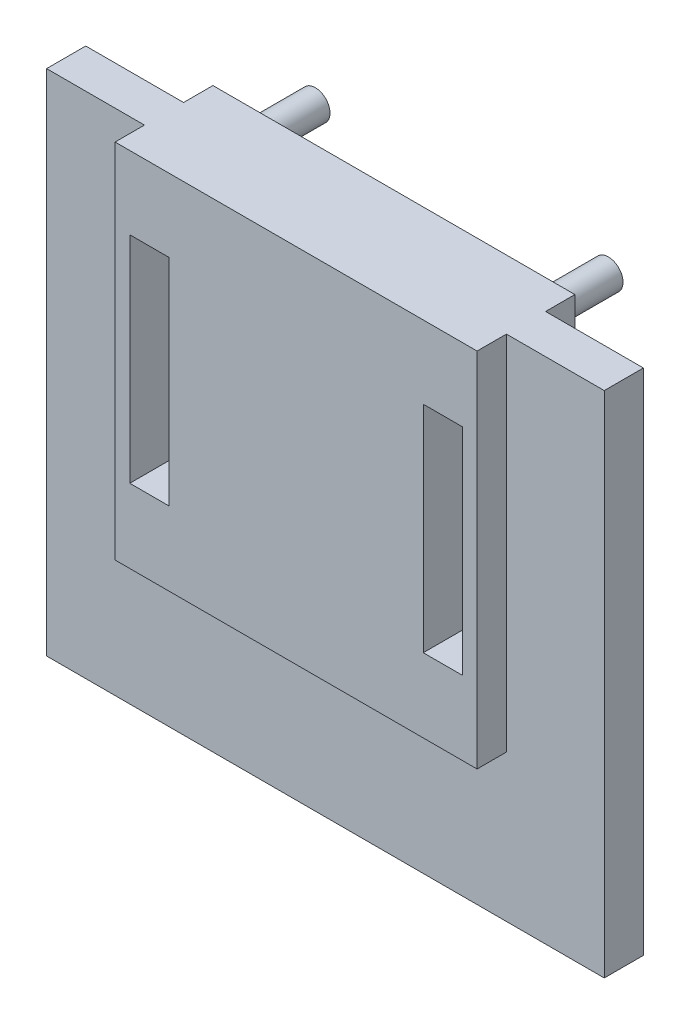
from build123d import *

# Parameters (mm, degrees)
SKETCH1_W           = 57
SKETCH1_H           = 52
BOSS_EXTRUDE1_DEPTH = 4
SKETCH3_W           = 37
SKETCH3_H           = 37
BOSS_EXTRUDE2_DEPTH = 3
SKETCH4_W           = 37
SKETCH4_H           = 37
BOSS_EXTRUDE3_DEPTH = 3
SKETCH6_R           = 1.5
BOSS_EXTRUDE4_DEPTH = 10
SKETCH6_6_R         = 1.5
BOSS_EXTRUDE6_DEPTH = 10
SKETCH8_W           = 4
SKETCH8_H           = 22
CUT_EXTRUDE1_DEPTH  = 40.852854352


with BuildPart() as part:
    # Sketch1 → Boss-Extrude1 (new body)
    with BuildSketch(Plane.XY):
        Rectangle(SKETCH1_W, SKETCH1_H)
    extrude(amount=BOSS_EXTRUDE1_DEPTH)

    # Sketch3 → Boss-Extrude2 (add)
    with BuildSketch(Plane.XY.offset(4)):
        with Locations((0, 7.5)):
            Rectangle(SKETCH3_W, SKETCH3_H)
    extrude(amount=BOSS_EXTRUDE2_DEPTH)

    # Sketch4 → Boss-Extrude3 (add)
    with BuildSketch(Plane(origin=(0, 0, 0), x_dir=(-1, 0, 0), z_dir=(0, 0, -1))):
        with Locations((0, 7.5)):
            Rectangle(SKETCH4_W, SKETCH4_H)
    extrude(amount=BOSS_EXTRUDE3_DEPTH)

    # Sketch6 → Boss-Extrude4 (add)
    with BuildSketch(Plane.XY):
        with Locations((14.91830134, 22.543210914)):
            Circle(SKETCH6_R)
        with Locations((14.91830134, -7.514403638)):
            Circle(SKETCH6_R)
    extrude(amount=-BOSS_EXTRUDE4_DEPTH)

    # Sketch6_6 → Boss-Extrude6 (add)
    with BuildSketch(Plane.XY):
        with Locations((-15.028807276, 22.543210914)):
            Circle(SKETCH6_6_R)
        with Locations((14.91830134, 22.543210914)):
            Circle(SKETCH6_6_R)
        with Locations((-15.028807276, -7.514403638)):
            Circle(SKETCH6_6_R)
        with Locations((14.91830134, -7.514403638)):
            Circle(SKETCH6_6_R)
    extrude(amount=-BOSS_EXTRUDE6_DEPTH)

    # Sketch8 → Cut-Extrude1 (cut, through all)
    with BuildSketch(Plane(origin=(0, 0, -3), x_dir=(-1, 0, 0), z_dir=(0, 0, -1))):
        with Locations((-15, 7.543210914)):
            Rectangle(SKETCH8_W, SKETCH8_H)
        with Locations((15, 7.543210914)):
            Rectangle(SKETCH8_W, SKETCH8_H)
    extrude(amount=-CUT_EXTRUDE1_DEPTH, mode=Mode.SUBTRACT)


solid = part.part
